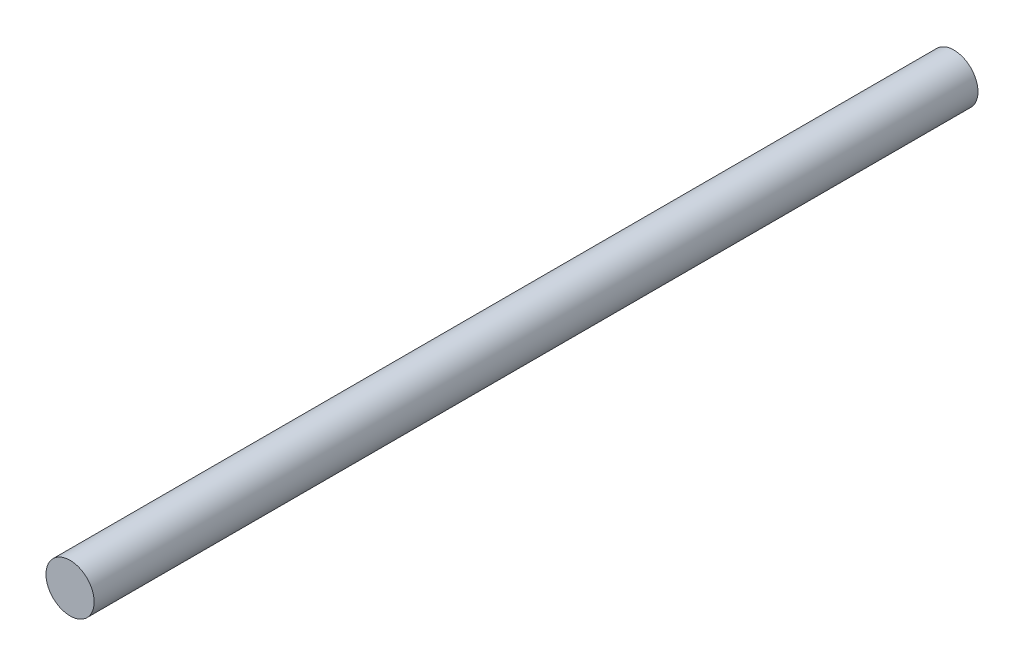
from build123d import *

# Parameters (mm, degrees)
SKETCH1_R           = 1.5
BOSS_EXTRUDE1_DEPTH = 55


with BuildPart() as part:
    # Sketch1 → Boss-Extrude1 (new body)
    with BuildSketch(Plane.XY):
        Circle(SKETCH1_R)
    extrude(amount=BOSS_EXTRUDE1_DEPTH)


solid = part.part
